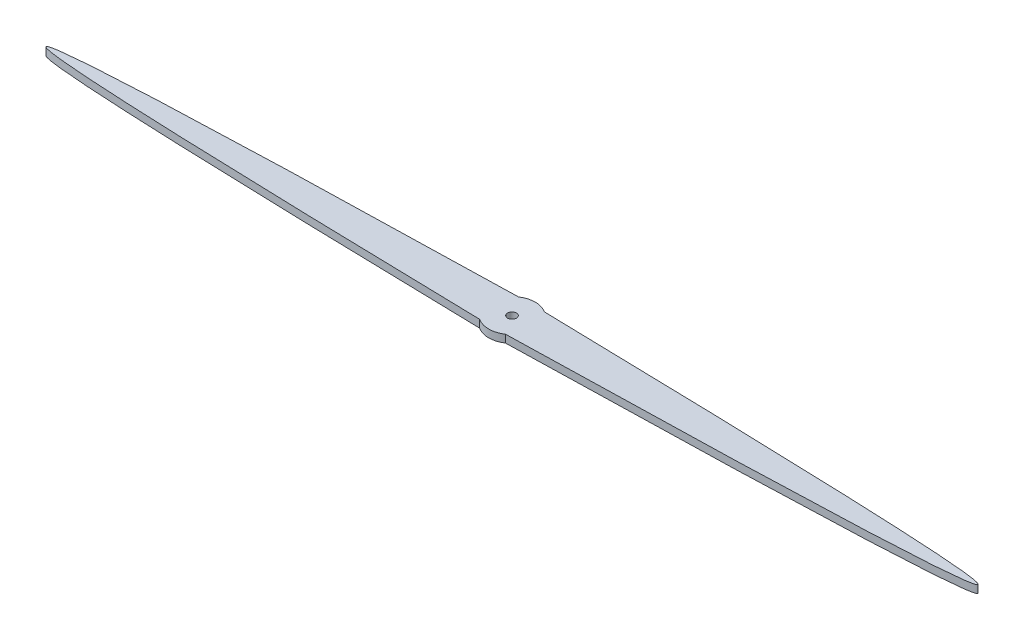
from build123d import *

# Parameters (mm, degrees)
SKETCH2_R           = 1.46304
BOSS_EXTRUDE1_DEPTH = 2.5146


with BuildPart() as part:
    # Sketch2 → Boss-Extrude1 (new body)
    with BuildSketch(Plane(origin=(0, 0, 0), x_dir=(1, 0, 0), z_dir=(0, 1, 0))):
        with BuildLine():
            ThreePointArc((-4.212113484, -6.35), (0, -7.62), (4.212113484, -6.35))
            add(Edge.make_bspline(
                [(4.212113484, 6.35), (300.587886516, 0), (4.212113484, -6.35)],
                knots=[0, 0, 0, 1, 1, 1], degree=2))
            ThreePointArc((4.212113484, 6.35), (0, 7.62), (-4.212113484, 6.35))
            add(Edge.make_bspline(
                [(-4.212113484, 6.35), (-300.587886516, 0), (-4.212113484, -6.35)],
                knots=[0, 0, 0, 1, 1, 1], degree=2))
        make_face()
        Circle(SKETCH2_R, mode=Mode.SUBTRACT)
    extrude(amount=BOSS_EXTRUDE1_DEPTH)


solid = part.part
